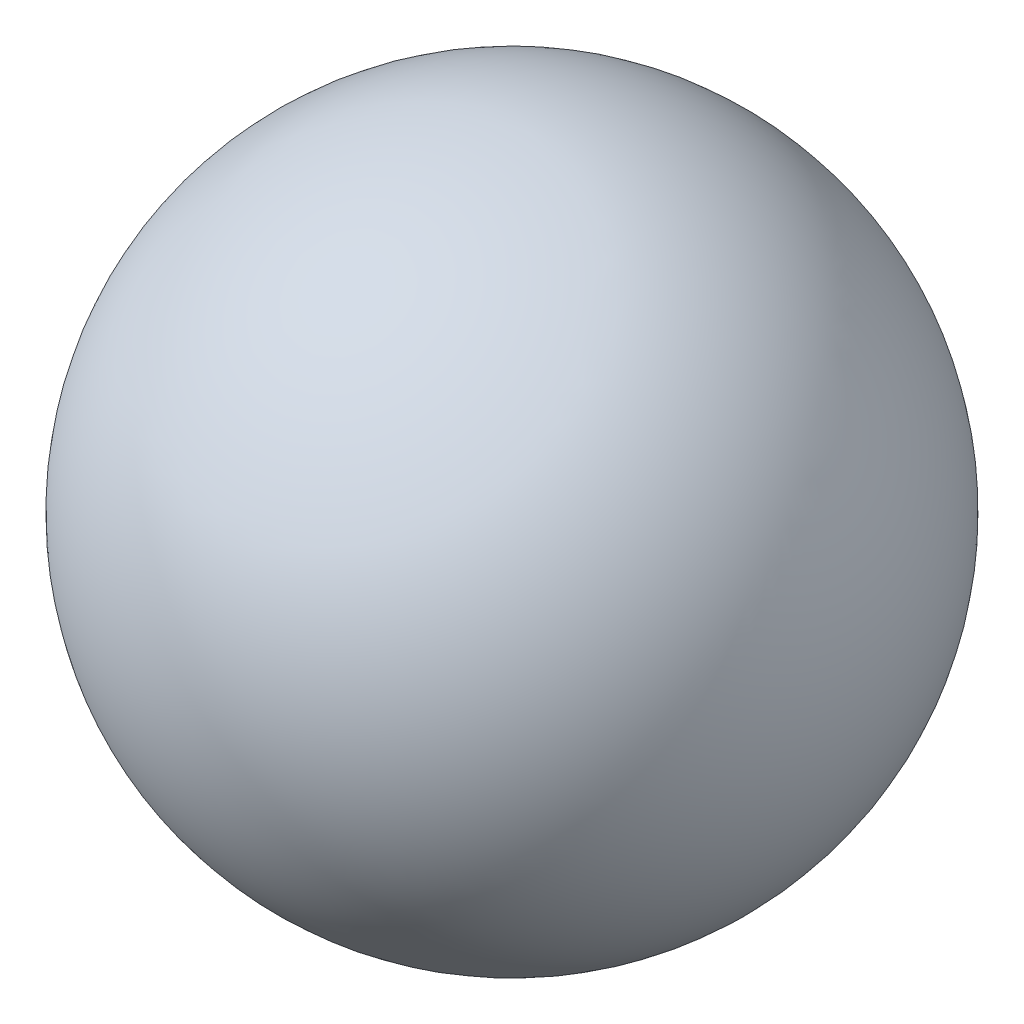
from build123d import *


with BuildPart() as part:
    # Sketch3 → Revolve1 (revolve)
    with BuildSketch(Plane.XY):
        with BuildLine():
            Line((52.522997744, 55.206654563), (-52.522997744, -55.206654563))
            ThreePointArc((-52.522997744, -55.206654563), (55.206654563, -52.522997744), (52.522997744, 55.206654563))
        make_face()
    revolve(axis=Axis((52.522997744, 55.206654563, 0), (-0.689278186, -0.724496779, 0)))


solid = part.part
